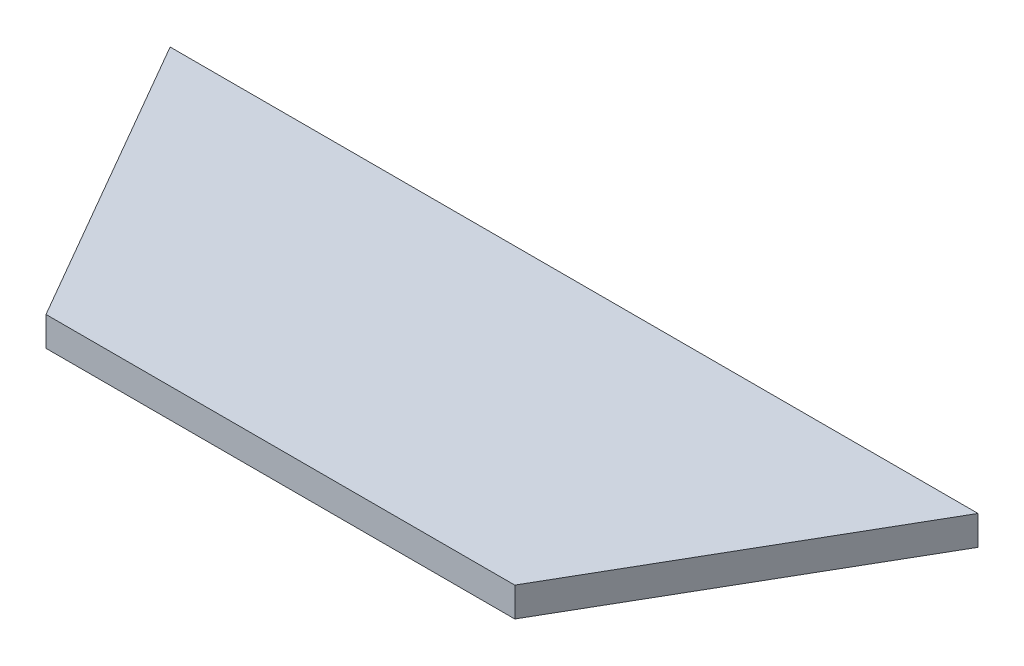
from build123d import *

# Parameters (mm, degrees)
EXTRUDE_1_DEPTH = 5


with BuildPart() as part:
    # Эскиз1 → Бобышка-Вытянуть1 (new body)
    with BuildSketch(Plane(origin=(0, 0, 0), x_dir=(1, 0, 0), z_dir=(0, 1, 0))):
        Polygon((0, 0), (79.81197846, 0), (108.679491919, 50), (-28.867513459, 50), align=None)
    extrude(amount=EXTRUDE_1_DEPTH)


solid = part.part
